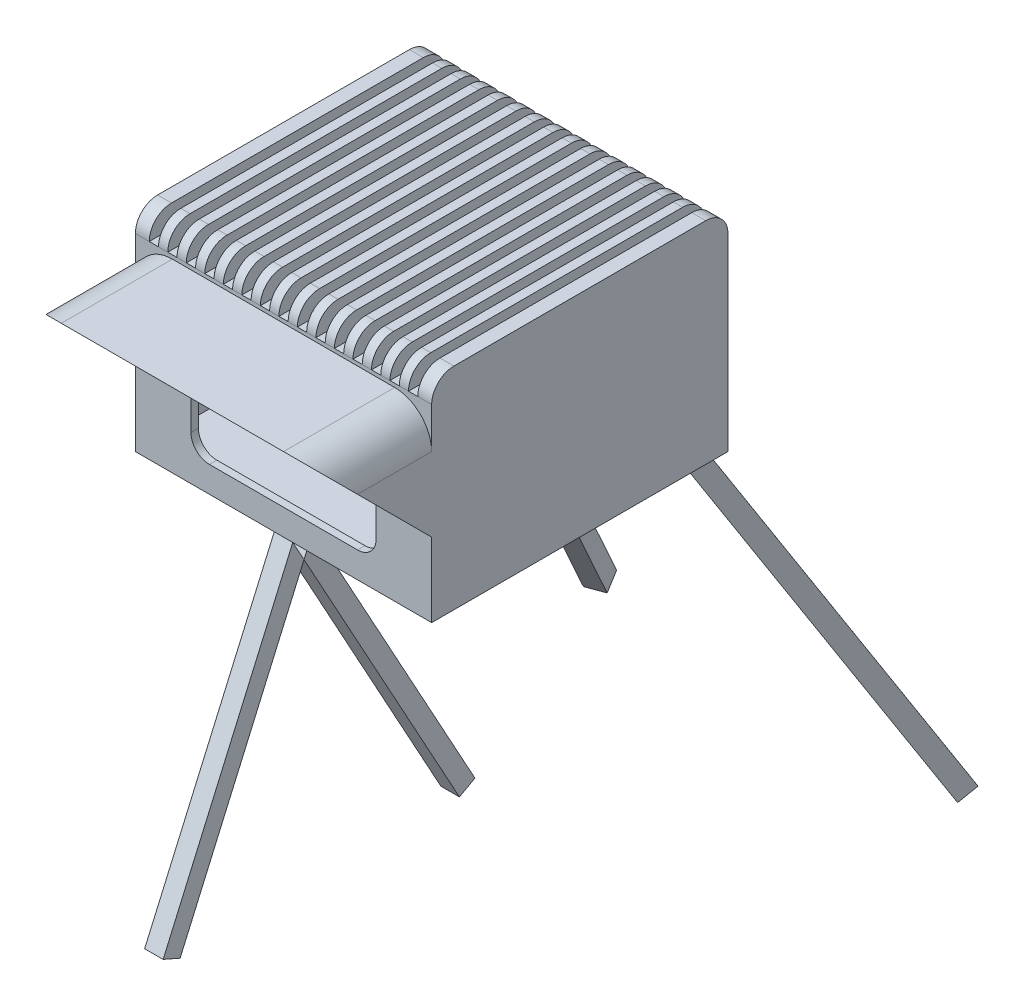
from build123d import *

# Parameters (mm, degrees)
SKETCH1_W             = 101.6
SKETCH1_H             = 101.6
BOSS_EXTRUDE1_DEPTH   = 63.5
SHELL1_T              = -2.54
CUT_EXTRUDE2_REACH    = 103.6
SKETCH4_W             = 76.2
SKETCH4_H             = 3.175
BOSS_EXTRUDE2_DEPTH   = 50.8
CUT_EXTRUDE3_REACH    = 78.2
SKETCH5_R             = 1.5875
BOSS_EXTRUDE3_DEPTH   = 19.05
BOSS_EXTRUDE4_DEPTH   = 38.1
CUT_EXTRUDE4_DEPTH    = 102.6
BOSS_EXTRUDE5_DEPTH   = 3.175
BOSS_EXTRUDE5_2_DEPTH = 3.175
BOSS_EXTRUDE6_DEPTH   = 3.175
SKETCH12_W            = 101.6
SKETCH12_H            = 101.6
BOSS_EXTRUDE7_DEPTH   = 8.89
SKETCH13_W            = 3.175
SKETCH13_H            = 101.6
CUT_EXTRUDE5_DEPTH    = 7.62
FILLET1_R             = 7.62


with BuildPart() as part:
    # Sketch1 → Boss-Extrude1 (new body)
    with BuildSketch(Plane(origin=(0, 0, 0), x_dir=(1, 0, 0), z_dir=(0, 1, 0))):
        Rectangle(SKETCH1_W, SKETCH1_H)
    extrude(amount=BOSS_EXTRUDE1_DEPTH)

    # Shell1
    shell1_openings = [part.faces().sort_by_distance(p)[0] for p in [
        (0, 63.5, 0),
    ]]
    offset(amount=SHELL1_T, openings=shell1_openings, kind=Kind.INTERSECTION)

    # Sketch3 → Cut-Extrude2 (cut, up to next)
    with BuildSketch(Plane.XY.offset(50.8), mode=Mode.PRIVATE) as cut_extrude2_sk1:
        with BuildLine():
            Line((-25.4, 46.99), (25.4, 46.99))
            ThreePointArc((25.4, 46.99), (29.890128061, 45.130128061), (31.75, 40.64))
            Line((31.75, 40.64), (31.75, 15.24))
            ThreePointArc((31.75, 15.24), (29.890128061, 10.749871939), (25.4, 8.89))
            Line((25.4, 8.89), (-25.4, 8.89))
            ThreePointArc((-25.4, 8.89), (-29.890128061, 10.749871939), (-31.75, 15.24))
            Line((-31.75, 15.24), (-31.75, 40.64))
            ThreePointArc((-31.75, 40.64), (-29.890128061, 45.130128061), (-25.4, 46.99))
        make_face()
    cut_extrude2_tool1 = extrude(cut_extrude2_sk1.sketch, amount=-CUT_EXTRUDE2_REACH, mode=Mode.PRIVATE) & part.part
    add(cut_extrude2_tool1.solids().sort_by_distance((0, 27.94, 50.8))[0], mode=Mode.SUBTRACT)

    # Sketch4 → Boss-Extrude2 (add)
    with BuildSketch(Plane(origin=(0, 2.54, 0), x_dir=(1, 0, 0), z_dir=(0, 1, 0))):
        with Locations((0, -23.8125)):
            Rectangle(SKETCH4_W, SKETCH4_H)
    extrude(amount=BOSS_EXTRUDE2_DEPTH)

    # Sketch5 → Cut-Extrude3 (cut, up to next)
    with BuildSketch(Plane.XY.offset(25.4), mode=Mode.PRIVATE) as cut_extrude3_sk1:
        with Locations((-25.4, 43.18)):
            Circle(SKETCH5_R)
    cut_extrude3_tool1 = extrude(cut_extrude3_sk1.sketch, amount=-CUT_EXTRUDE3_REACH, mode=Mode.PRIVATE) & part.part
    add(cut_extrude3_tool1.solids().sort_by_distance((-25.4, 43.18, 25.4))[0], mode=Mode.SUBTRACT)
    # Sketch5 → Cut-Extrude3 (cut, up to next)
    with BuildSketch(Plane.XY.offset(25.4), mode=Mode.PRIVATE) as cut_extrude3_sk2:
        with Locations((25.4, 43.18)):
            Circle(SKETCH5_R)
    cut_extrude3_tool2 = extrude(cut_extrude3_sk2.sketch, amount=-CUT_EXTRUDE3_REACH, mode=Mode.PRIVATE) & part.part
    add(cut_extrude3_tool2.solids().sort_by_distance((25.4, 43.18, 25.4))[0], mode=Mode.SUBTRACT)

    # Sketch6 → Boss-Extrude3 (add)
    with BuildSketch(Plane(origin=(0, 63.5, 0), x_dir=(1, 0, 0), z_dir=(0, 1, 0))):
        with BuildLine():
            Line((-48.26, -39.37), (-48.26, -48.26))
            Line((-48.26, -48.26), (-39.37, -48.26))
            ThreePointArc((-39.37, -48.26), (-41.973820715, -41.973820715), (-48.26, -39.37))
        make_face()
        with BuildLine():
            Line((39.37, -48.26), (48.26, -48.26))
            Line((48.26, -48.26), (48.26, -39.37))
            ThreePointArc((48.26, -39.37), (41.973820715, -41.973820715), (39.37, -48.26))
        make_face()
        with BuildLine():
            Line((48.26, 39.37), (48.26, 48.26))
            Line((48.26, 48.26), (39.37, 48.26))
            ThreePointArc((39.37, 48.26), (41.973820715, 41.973820715), (48.26, 39.37))
        make_face()
        with BuildLine():
            Line((-48.26, 39.37), (-48.26, 48.26))
            Line((-48.26, 48.26), (-39.37, 48.26))
            ThreePointArc((-39.37, 48.26), (-41.973820715, 41.973820715), (-48.26, 39.37))
        make_face()
    extrude(amount=-BOSS_EXTRUDE3_DEPTH)

    # Sketch7 → Boss-Extrude4 (add)
    with BuildSketch(Plane.XY.offset(50.8)):
        with BuildLine():
            Line((38.1, 63.5), (-38.1, 63.5))
            ThreePointArc((-38.1, 63.5), (-47.080256121, 59.780256121), (-50.8, 50.8))
            Line((-50.8, 50.8), (-50.8, 25.4))
            Line((-50.8, 25.4), (-49.2125, 25.4))
            Line((-49.2125, 25.4), (-49.2125, 50.8))
            ThreePointArc((-49.2125, 50.8), (-45.957724106, 58.657724106), (-38.1, 61.9125))
            Line((-38.1, 61.9125), (38.1, 61.9125))
            ThreePointArc((38.1, 61.9125), (45.957724106, 58.657724106), (49.2125, 50.8))
            Line((49.2125, 50.8), (49.2125, 25.4))
            Line((49.2125, 25.4), (50.8, 25.4))
            Line((50.8, 25.4), (50.8, 50.8))
            ThreePointArc((50.8, 50.8), (47.080256121, 59.780256121), (38.1, 63.5))
        make_face()
    extrude(amount=BOSS_EXTRUDE4_DEPTH)

    # Sketch8 → Cut-Extrude4 (cut, through all)
    with BuildSketch(Plane.ZY.offset(50.8)):
        Polygon((50.8, 25.4), (88.9, 63.5), (88.9, 25.4), align=None)
    extrude(amount=-CUT_EXTRUDE4_DEPTH, mode=Mode.SUBTRACT)

    # Sketch11 → Boss-Extrude6 (add, symmetric)
    with BuildSketch(Plane(origin=(16.326805286, 0, 5.942471145), x_dir=(0.342020143, 0, -0.939692621), z_dir=(0.939692621, 0, 0.342020143))):
        Polygon((60.384076548, 0), (136.584076548, -127), (131.138996469, -130.267048047), (52.978767641, 0), align=None)
    boss_extrude6 = extrude(amount=BOSS_EXTRUDE6_DEPTH, both=True)

    # Mirror1: Boss-Extrude6 across plane
    add(boss_extrude6.mirror(Plane(origin=(0, 0, 0), x_dir=(0, 0, 1), z_dir=(1, 0, 0))))

    # Sketch12 → Boss-Extrude7 (add)
    with BuildSketch(Plane(origin=(0, 63.5, 0), x_dir=(1, 0, 0), z_dir=(0, 1, 0))):
        Rectangle(SKETCH12_W, SKETCH12_H)
    extrude(amount=BOSS_EXTRUDE7_DEPTH)

    # Sketch13 → Cut-Extrude5 (cut)
    with BuildSketch(Plane(origin=(0, 72.39, 0), x_dir=(1, 0, 0), z_dir=(0, 1, 0))):
        Rectangle(SKETCH13_W, SKETCH13_H)
        with Locations((-6.35, 0)):
            Rectangle(SKETCH13_W, SKETCH13_H)
        with Locations((-12.7, 0)):
            Rectangle(SKETCH13_W, SKETCH13_H)
        with Locations((-19.05, 0)):
            Rectangle(SKETCH13_W, SKETCH13_H)
        with Locations((-25.4, 0)):
            Rectangle(SKETCH13_W, SKETCH13_H)
        with Locations((-31.75, 0)):
            Rectangle(SKETCH13_W, SKETCH13_H)
        with Locations((-38.1, 0)):
            Rectangle(SKETCH13_W, SKETCH13_H)
        with Locations((-44.45, 0)):
            Rectangle(SKETCH13_W, SKETCH13_H)
        with Locations((6.35, 0)):
            Rectangle(SKETCH13_W, SKETCH13_H)
        with Locations((12.7, 0)):
            Rectangle(SKETCH13_W, SKETCH13_H)
        with Locations((19.05, 0)):
            Rectangle(SKETCH13_W, SKETCH13_H)
        with Locations((25.4, 0)):
            Rectangle(SKETCH13_W, SKETCH13_H)
        with Locations((31.75, 0)):
            Rectangle(SKETCH13_W, SKETCH13_H)
        with Locations((38.1, 0)):
            Rectangle(SKETCH13_W, SKETCH13_H)
        with Locations((44.45, 0)):
            Rectangle(SKETCH13_W, SKETCH13_H)
    extrude(amount=-CUT_EXTRUDE5_DEPTH, mode=Mode.SUBTRACT)

    # Fillet1
    fillet1_edges = [part.edges().sort_by_distance(p)[0] for p in [
        (48.41875, 72.39, -50.8),
        (41.275, 72.39, -50.8),
        (34.925, 72.39, -50.8),
        (28.575, 72.39, -50.8),
        (22.225, 72.39, -50.8),
        (15.875, 72.39, -50.8),
        (9.525, 72.39, -50.8),
        (3.175, 72.39, -50.8),
        (-3.175, 72.39, -50.8),
        (-9.525, 72.39, -50.8),
        (-15.875, 72.39, -50.8),
        (-22.225, 72.39, -50.8),
        (-28.575, 72.39, -50.8),
        (-34.925, 72.39, -50.8),
        (-41.275, 72.39, -50.8),
        (-48.41875, 72.39, -50.8),
        (48.41875, 72.39, 50.8),
        (41.275, 72.39, 50.8),
        (34.925, 72.39, 50.8),
        (28.575, 72.39, 50.8),
        (22.225, 72.39, 50.8),
        (15.875, 72.39, 50.8),
        (9.525, 72.39, 50.8),
        (3.175, 72.39, 50.8),
        (-3.175, 72.39, 50.8),
        (-9.525, 72.39, 50.8),
        (-15.875, 72.39, 50.8),
        (-22.225, 72.39, 50.8),
        (-28.575, 72.39, 50.8),
        (-34.925, 72.39, 50.8),
        (-41.275, 72.39, 50.8),
        (-48.41875, 72.39, 50.8),
    ]]
    fillet(fillet1_edges, radius=FILLET1_R)


with BuildPart() as body_2:
    # Sketch9 → Boss-Extrude5 (new body, symmetric)
    with BuildSketch(Plane(origin=(0, 0, 0), x_dir=(0, 0, -1), z_dir=(1, 0, 0))):
        Polygon((11.677003567, -101.221989933), (-43.8688761, 0), (-46.943509518, -7.027733526), (6.35, -104.145199596), align=None)
    extrude(amount=BOSS_EXTRUDE5_DEPTH, both=True)


with BuildPart() as body_3:
    # Sketch9 → Boss-Extrude5 2 (new body, symmetric)
    with BuildSketch(Plane(origin=(0, 0, 0), x_dir=(0, 0, -1), z_dir=(1, 0, 0))):
        Polygon((-46.943509518, -7.027733526), (-50.8, 0), (-95.25, -101.6), (-89.432400923, -104.145199596), align=None)
    extrude(amount=BOSS_EXTRUDE5_2_DEPTH, both=True)


solid = Compound([part.part, body_2.part, body_3.part])
